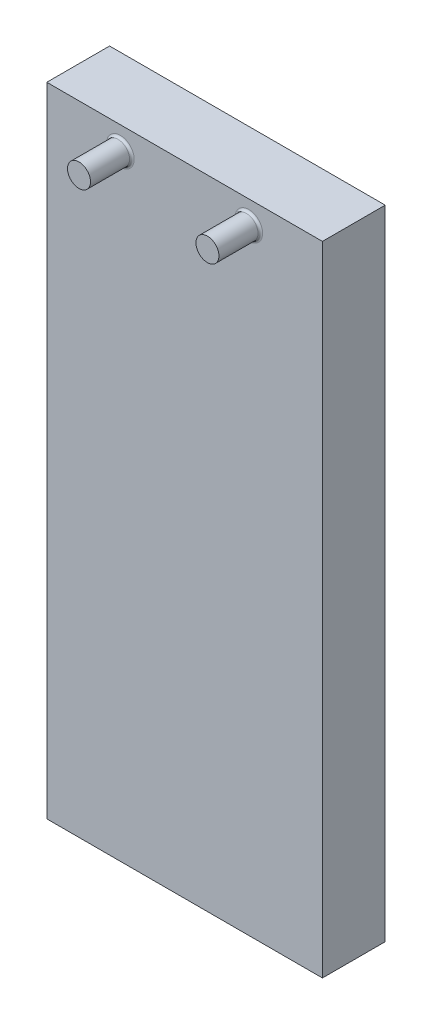
from build123d import *

# Parameters (mm, degrees)
SKETCH1_W           = 119.84
SKETCH1_H           = 27.3
BOSS_EXTRUDE1_DEPTH = 277.37
SKETCH2_R           = 5
BOSS_EXTRUDE2_DEPTH = 18
FILLET1_R           = 1


with BuildPart() as part:
    # Sketch1 → Boss-Extrude1 (new body)
    with BuildSketch(Plane(origin=(0, 0, 0), x_dir=(1, 0, 0), z_dir=(0, 1, 0))):
        Rectangle(SKETCH1_W, SKETCH1_H)
    extrude(amount=BOSS_EXTRUDE1_DEPTH)

    # Sketch2 → Boss-Extrude2 (add)
    with BuildSketch(Plane.XY.offset(13.65)):
        with Locations((-27.92, 267.37)):
            Circle(SKETCH2_R)
        with Locations((27.92, 267.37)):
            Circle(SKETCH2_R)
    extrude(amount=BOSS_EXTRUDE2_DEPTH)

    # Fillet1
    fillet1_edges = [part.edges().sort_by_distance(p)[0] for p in [
        (22.92, 267.37, 13.65),
        (-32.92, 267.37, 13.65),
    ]]
    fillet(fillet1_edges, radius=FILLET1_R)


solid = part.part
